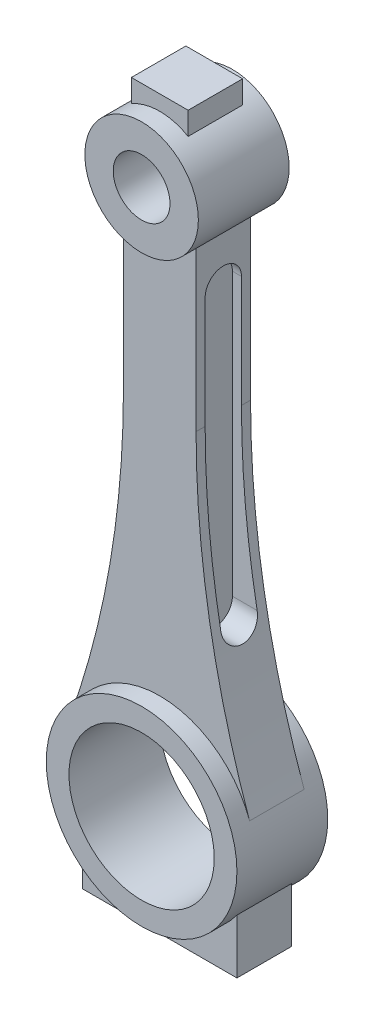
from build123d import *

# Parameters (mm, degrees)
SKETCH1_R             = 21
SKETCH1_R_2           = 16
BOSS_EXTRUDE2_DEPTH   = 10
SKETCH1_R_3           = 12.5
SKETCH1_R_4           = 6.25
BOSS_EXTRUDE2_2_DEPTH = 10
BOSS_EXTRUDE3_DEPTH   = 6
CUT_EXTRUDE3_START    = -6
CUT_EXTRUDE3_DEPTH    = 16
CUT_EXTRUDE4_START    = 6
CUT_EXTRUDE4_DEPTH    = 16


with BuildPart() as part:
    # Sketch1 → Boss-Extrude2 (new body, symmetric)
    with BuildSketch(Plane.XY):
        Circle(SKETCH1_R)
        Circle(SKETCH1_R_2, mode=Mode.SUBTRACT)
    extrude(amount=BOSS_EXTRUDE2_DEPTH, both=True)



with BuildPart() as body_2:
    # Sketch1 → Boss-Extrude2 2 (new body, symmetric)
    with BuildSketch(Plane.XY):
        with Locations((0, 120)):
            Circle(SKETCH1_R_3)
        with Locations((0, 120)):
            Circle(SKETCH1_R_4, mode=Mode.SUBTRACT)
    extrude(amount=BOSS_EXTRUDE2_2_DEPTH, both=True)


with BuildPart() as part_1:
    add(part.part)

    add(body_2.part)  # Boss-Extrude3 merges body 2
    # Sketch1_4 → Boss-Extrude3 (add, symmetric)
    with BuildSketch(Plane.XY):
        with BuildLine():
            Line((-8, 110.395313644), (-8, 75.395313644))
            ThreePointArc((-8, 75.395313644), (-10.96842855, 40.709642053), (-19.787382488, 7.032744434))
            ThreePointArc((-19.787382488, 7.032744434), (0, 21), (19.787382488, 7.032744434))
            ThreePointArc((19.787382488, 7.032744434), (10.96842855, 40.709642053), (8, 75.395313644))
            Line((8, 75.395313644), (8, 110.395313644))
            ThreePointArc((8, 110.395313644), (0, 107.5), (-8, 110.395313644))
        make_face()
        with BuildLine():
            Line((-6.25, 135.825317547), (-6.25, 130.825317547))
            ThreePointArc((-6.25, 130.825317547), (0, 132.5), (6.25, 130.825317547))
            Line((6.25, 130.825317547), (6.25, 135.825317547))
            Line((6.25, 135.825317547), (-6.25, 135.825317547))
        make_face()
        with BuildLine():
            ThreePointArc((17, -12.328828006), (0, -21), (-17, -12.328828006))
            Line((-17, -12.328828006), (-17, -24.328828006))
            Line((-17, -24.328828006), (17, -24.328828006))
            Line((17, -24.328828006), (17, -12.328828006))
        make_face()
    extrude(amount=BOSS_EXTRUDE3_DEPTH, both=True)

    # Sketch4 → Cut-Extrude3 (cut, through all)
    with BuildSketch(Plane(origin=(0, 0, 0), x_dir=(0, 0, -1), z_dir=(1, 0, 0)).offset(CUT_EXTRUDE3_START)):
        with BuildLine():
            Line((4, 38), (4, 100))
            ThreePointArc((4, 100), (0, 104), (-4, 100))
            Line((-4, 100), (-4, 38))
            ThreePointArc((-4, 38), (0, 34), (4, 38))
        make_face()
    extrude(amount=-CUT_EXTRUDE3_DEPTH, mode=Mode.SUBTRACT)

    # Sketch4_2 → Cut-Extrude4 (cut, through all)
    with BuildSketch(Plane(origin=(0, 0, 0), x_dir=(0, 0, -1), z_dir=(1, 0, 0)).offset(CUT_EXTRUDE4_START)):
        with BuildLine():
            Line((4, 38), (4, 100))
            ThreePointArc((4, 100), (0, 104), (-4, 100))
            Line((-4, 100), (-4, 38))
            ThreePointArc((-4, 38), (0, 34), (4, 38))
        make_face()
    extrude(amount=CUT_EXTRUDE4_DEPTH, mode=Mode.SUBTRACT)


solid = part_1.part
